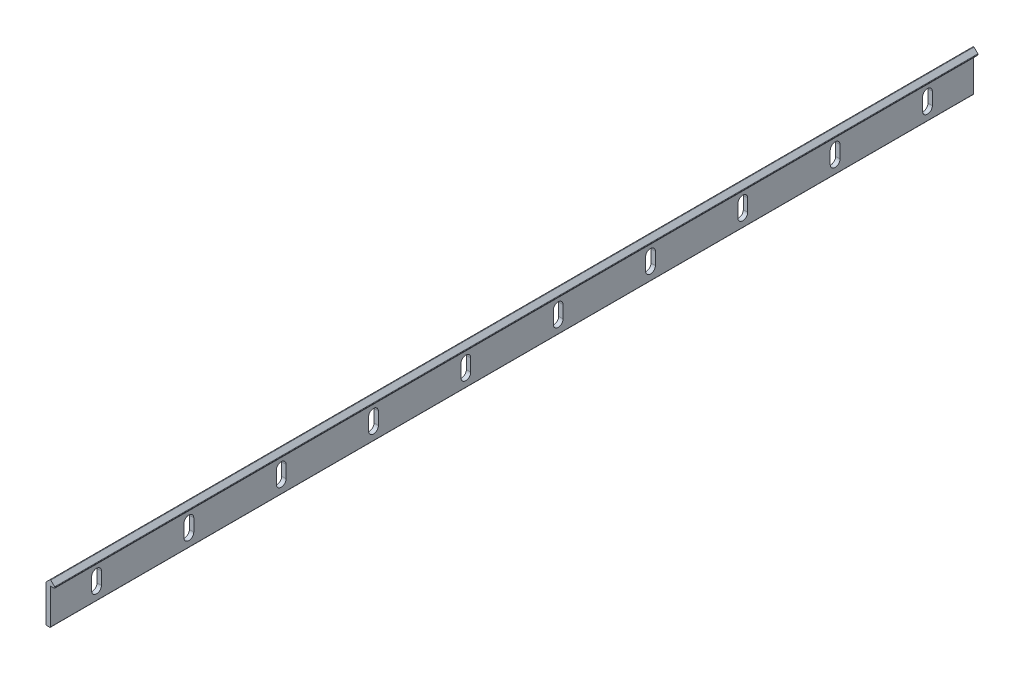
from build123d import *

# Parameters (mm, degrees)
BOSS_EXTRUDE1_DEPTH = 500
CUT_EXTRUDE1_DEPTH  = 3.375
LPATTERN1_COUNT     = 10
LPATTERN1_PITCH     = 50


with BuildPart() as part:
    # Sketch1 → Boss-Extrude1 (new body)
    with BuildSketch(Plane.XY):
        with BuildLine():
            Line((0, 0.3), (0, 20.125))
            ThreePointArc((0, 20.125), (0.02283614, 20.23980503), (0.087867966, 20.337132034))
            Line((0.087867966, 20.337132034), (2.162867966, 22.412132034))
            ThreePointArc((2.162867966, 22.412132034), (2.375, 22.5), (2.587132034, 22.412132034))
            Line((2.587132034, 22.412132034), (4.662132034, 20.337132034))
            ThreePointArc((4.662132034, 20.337132034), (4.72716386, 20.23980503), (4.75, 20.125))
            Line((4.75, 20.125), (4.75, 19.85))
            ThreePointArc((4.75, 19.85), (4.662132034, 19.637867966), (4.45, 19.55))
            Line((4.45, 19.55), (2.375, 19.55))
            Line((2.375, 19.55), (2.375, 0.3))
            ThreePointArc((2.375, 0.3), (2.287132034, 0.087867966), (2.075, 0))
            Line((2.075, 0), (0.3, 0))
            ThreePointArc((0.3, 0), (0.087867966, 0.087867966), (0, 0.3))
        make_face()
    extrude(amount=BOSS_EXTRUDE1_DEPTH)

    # Sketch2 → Cut-Extrude1 (cut, through all)
    with BuildSketch(Plane(origin=(2.375, 0, 0), x_dir=(0, 0, -1), z_dir=(1, 0, 0))):
        with BuildLine():
            Line((-22.35, 12.7), (-22.35, 6))
            ThreePointArc((-22.35, 6), (-25, 3.35), (-27.65, 6))
            Line((-27.65, 6), (-27.65, 12.7))
            ThreePointArc((-27.65, 12.7), (-25, 15.35), (-22.35, 12.7))
        make_face()
    cut_extrude1 = extrude(amount=-CUT_EXTRUDE1_DEPTH, mode=Mode.SUBTRACT)

    # LPattern1: Cut-Extrude1 ×10
    with Locations(*[(0, 0, i * LPATTERN1_PITCH) for i in range(1, LPATTERN1_COUNT)]):
        add(cut_extrude1, mode=Mode.SUBTRACT)


solid = part.part
